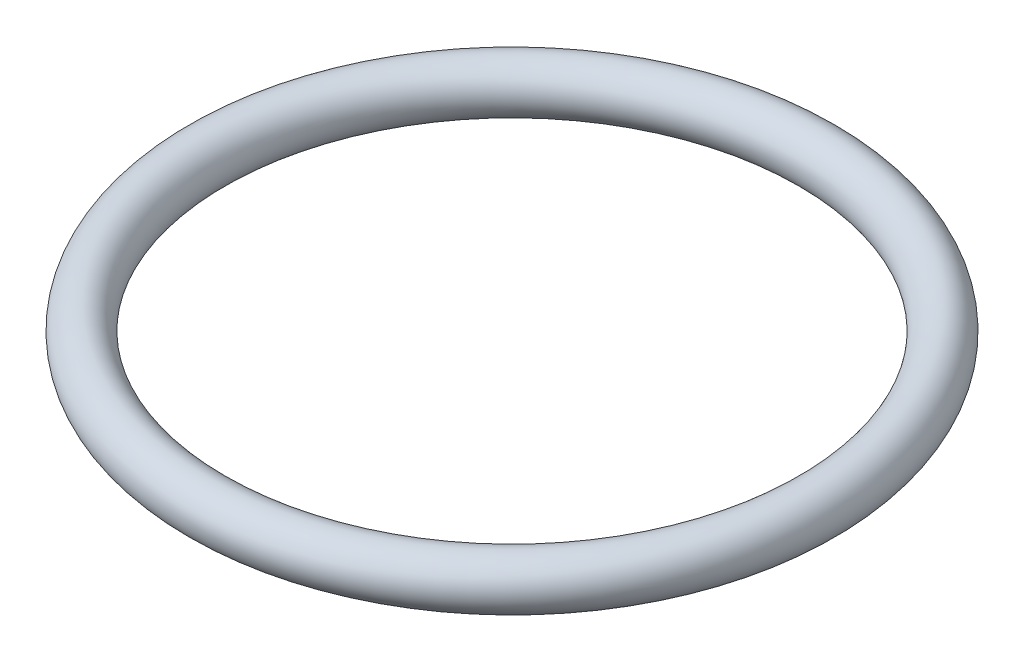
from build123d import *

# Parameters (mm, degrees)
SKETCH3_R = 0.7


with BuildPart() as part:
    # Sketch3 → Revolve1 (revolve)
    with BuildSketch(Plane.XY):
        with Locations((8.5, 0)):
            Circle(SKETCH3_R)
    revolve(axis=Axis((0, 0, 0), (0, 1, 0)))


solid = part.part
